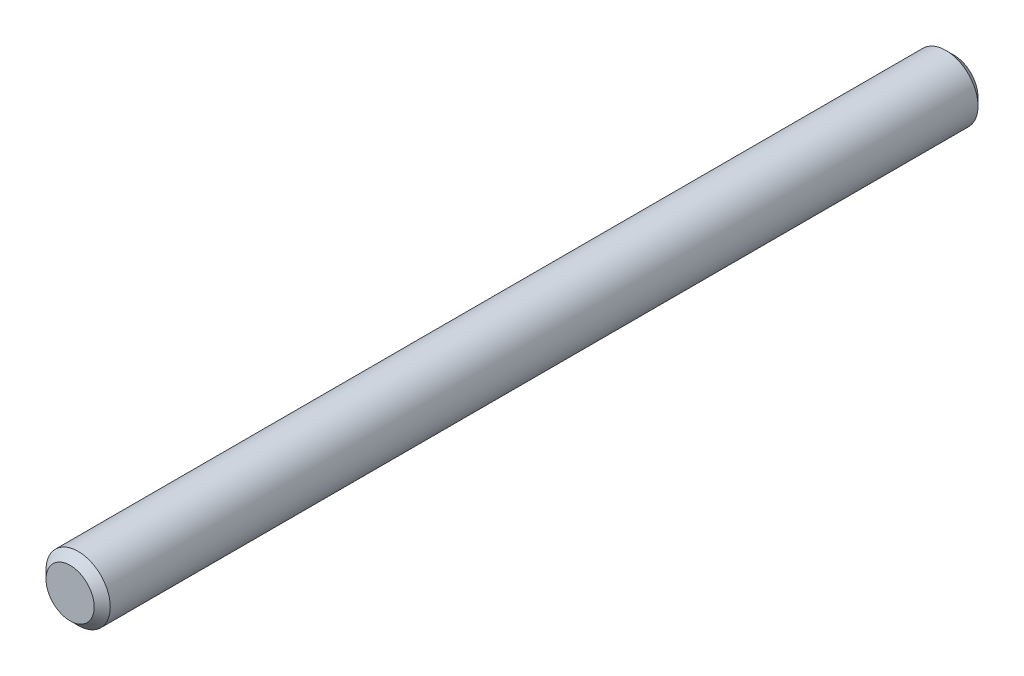
from build123d import *

# Parameters (mm, degrees)
ESQUISSE1_R        = 0.4
BOSS_EXTRU_1_DEPTH = 11
CHANFREIN1_SIZE    = 0.1


with BuildPart() as part:
    # Esquisse1 → Boss.-Extru.1 (new body)
    with BuildSketch(Plane.XY):
        Circle(ESQUISSE1_R)
    extrude(amount=BOSS_EXTRU_1_DEPTH)

    # Chanfrein1
    chanfrein1_edges = [part.edges().sort_by_distance(p)[0] for p in [
        (-0.4, 0, 0),
        (-0.4, 0, 11),
    ]]
    chamfer(chanfrein1_edges, length=CHANFREIN1_SIZE)


solid = part.part
